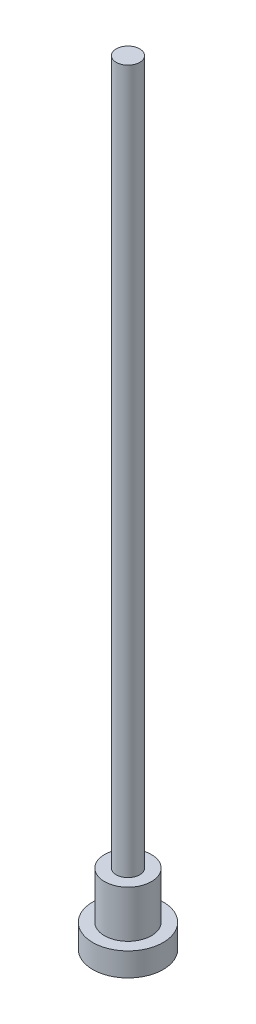
from build123d import *

# Parameters (mm, degrees)
SKETCH1_R           = 1.5
BOSS_EXTRUDE1_DEPTH = 1
SKETCH2_R           = 1
BOSS_EXTRUDE3_DEPTH = 2
SKETCH3_R           = 0.5
BOSS_EXTRUDE4_DEPTH = 30


with BuildPart() as part:
    # Sketch1 → Boss-Extrude1 (new body)
    with BuildSketch(Plane(origin=(0, 0, 0), x_dir=(1, 0, 0), z_dir=(0, 1, 0))):
        Circle(SKETCH1_R)
    extrude(amount=BOSS_EXTRUDE1_DEPTH)

    # Sketch2 → Boss-Extrude3 (add)
    with BuildSketch(Plane(origin=(0, 1, 0), x_dir=(1, 0, 0), z_dir=(0, 1, 0))):
        Circle(SKETCH2_R)
    extrude(amount=BOSS_EXTRUDE3_DEPTH)

    # Sketch3 → Boss-Extrude4 (add)
    with BuildSketch(Plane(origin=(0, 3, 0), x_dir=(1, 0, 0), z_dir=(0, 1, 0))):
        Circle(SKETCH3_R)
    extrude(amount=BOSS_EXTRUDE4_DEPTH)


solid = part.part
